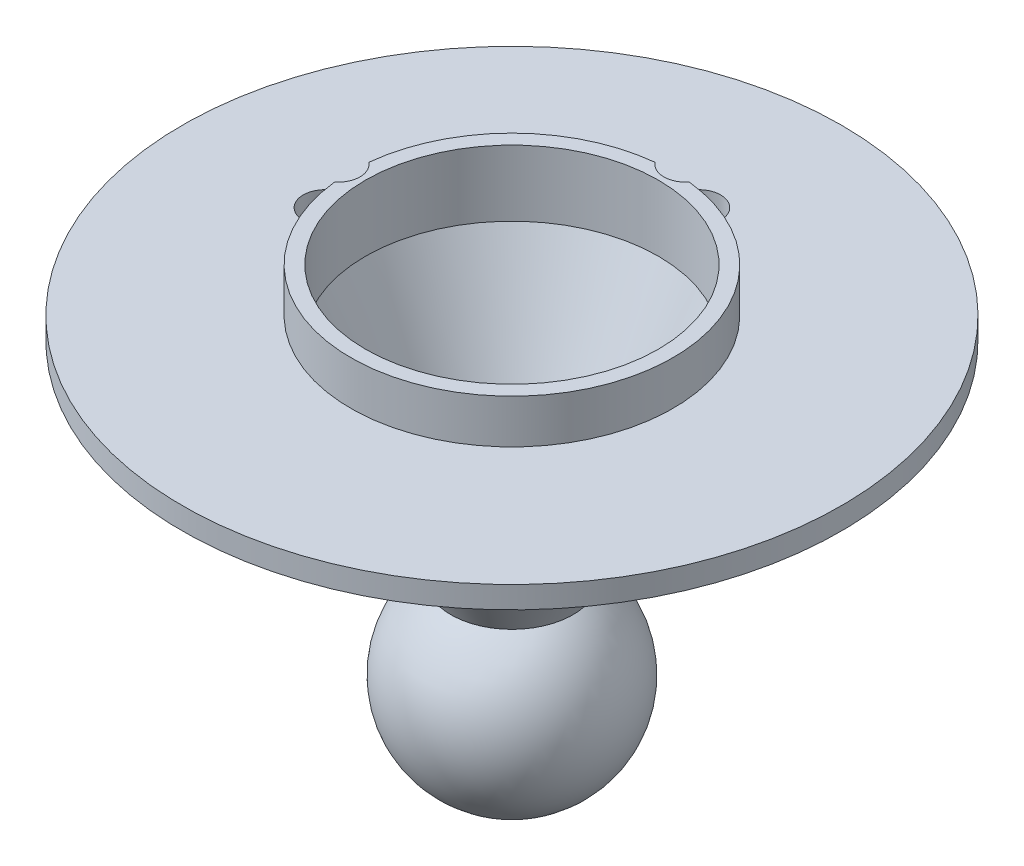
from build123d import *

# Parameters (mm, degrees)
CUT_EXTRUDE1_REACH             = 85.293
CUT_EXTRUDE1_DIRECTION_2_DEPTH = 10
CIRPATTERN1_COUNT              = 2
CIRPATTERN1_ANGLE              = 90


with BuildPart() as part:
    # Sketch1 → Revolve1 (revolve)
    with BuildSketch(Plane.XY):
        with BuildLine():
            Line((-6.832916656, 22.5), (-6.832916656, 0))
            Line((-6.832916656, 0), (-8.332916656, 0))
            ThreePointArc((-8.332916656, 0), (-14, 11.25), (-8.332916656, 22.5))
            Line((-8.332916656, 22.5), (-24.635499254, 50.736901354))
            Line((-24.635499254, 50.736901354), (-45, 50.736901354))
            Line((-45, 50.736901354), (-45, 53.736901354))
            Line((-45, 53.736901354), (-22, 53.736901354))
            Line((-22, 53.736901354), (-22, 59.736901354))
            Line((-22, 59.736901354), (-20, 59.736901354))
            Line((-20, 59.736901354), (-20, 50.736901354))
            Line((-20, 50.736901354), (-6.832916656, 22.5))
        make_face()
    revolve(axis=Axis((0, -17.773369394, 0), (0, 1, 0)))

    # Sketch2 → Cut-Extrude1 (cut, up to next)
    with BuildSketch(Plane(origin=(0, 53.736901354, 0), x_dir=(1, 0, 0), z_dir=(0, 1, 0)), mode=Mode.PRIVATE) as cut_extrude1_sk1:
        with BuildLine():
            Line((-23.75, 3), (-25.5, 3))
            ThreePointArc((-25.5, 3), (-28.5, 0), (-25.5, -3))
            Line((-25.5, -3), (-23.75, -3))
            ThreePointArc((-23.75, -3), (-20.75, 0), (-23.75, 3))
        make_face()
    cut_extrude1_tool1 = extrude(cut_extrude1_sk1.sketch, amount=-CUT_EXTRUDE1_REACH, mode=Mode.PRIVATE) & part.part
    cut_extrude1 = cut_extrude1_tool1.solids().sort_by_distance((-24.625, 53.736901, 0))[0]
    add(cut_extrude1, mode=Mode.SUBTRACT)

    # Sketch2 → Cut-Extrude1 direction 2 (cut)
    with BuildSketch(Plane(origin=(0, 53.736901354, 0), x_dir=(1, 0, 0), z_dir=(0, 1, 0))):
        with BuildLine():
            Line((-23.75, 3), (-25.5, 3))
            ThreePointArc((-25.5, 3), (-28.5, 0), (-25.5, -3))
            Line((-25.5, -3), (-23.75, -3))
            ThreePointArc((-23.75, -3), (-20.75, 0), (-23.75, 3))
        make_face()
    cut_extrude1_direction_2 = extrude(amount=CUT_EXTRUDE1_DIRECTION_2_DEPTH, mode=Mode.SUBTRACT)

    # CirPattern1: Cut-Extrude1, Cut-Extrude1 direction 2 ×2 about axis
    cirpattern1_axis = Axis((0, 22.5, 0), (0, -1, 0))
    add([cut_extrude1.rotate(cirpattern1_axis, i * CIRPATTERN1_ANGLE / (CIRPATTERN1_COUNT - 1)) for i in range(1, CIRPATTERN1_COUNT)], mode=Mode.SUBTRACT)
    add([cut_extrude1_direction_2.rotate(cirpattern1_axis, i * CIRPATTERN1_ANGLE / (CIRPATTERN1_COUNT - 1)) for i in range(1, CIRPATTERN1_COUNT)], mode=Mode.SUBTRACT)


solid = part.part
